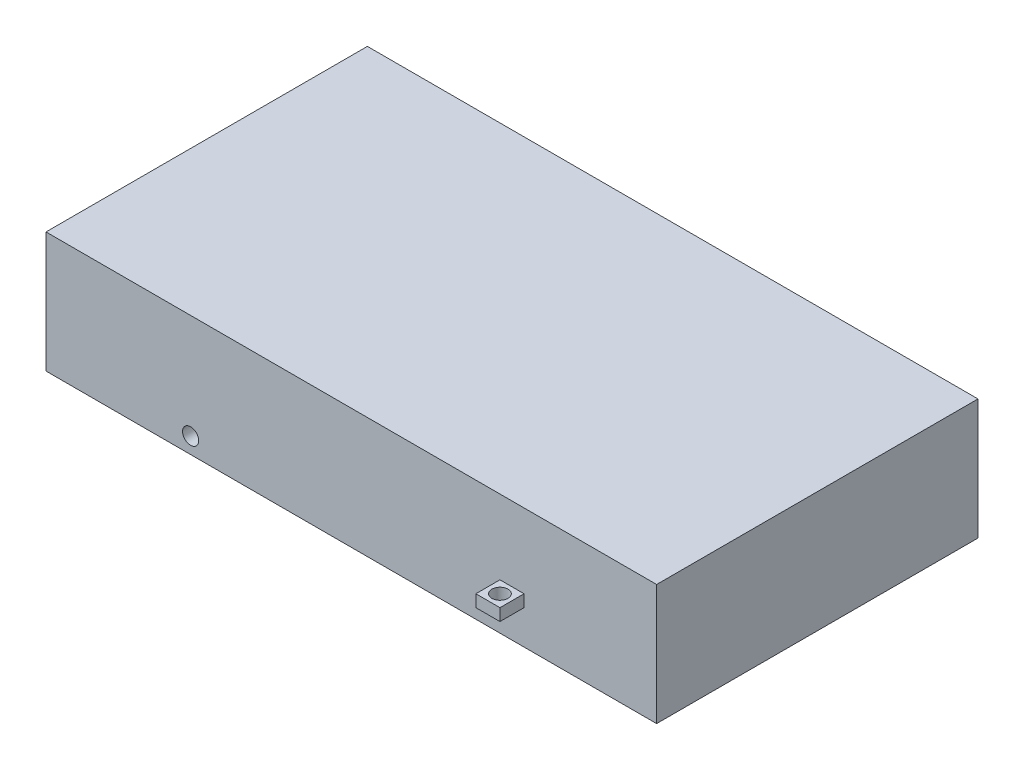
from build123d import *

# Parameters (mm, degrees)
SKETCH1_W           = 965.2
SKETCH1_H           = 508
BOSS_EXTRUDE1_DEPTH = 190.5
SKETCH2_W           = 38.1
SKETCH2_H           = 19.05
BOSS_EXTRUDE3_DEPTH = 38.1
CUT_EXTRUDE1_REACH  = 578.217
SKETCH3_R           = 12.7
CUT_EXTRUDE2_REACH  = 728.125
SKETCH2_4_R         = 12.7


with BuildPart() as part:
    # Sketch1 → Boss-Extrude1 (new body)
    with BuildSketch(Plane(origin=(0, 0, 0), x_dir=(1, 0, 0), z_dir=(0, 1, 0))):
        Rectangle(SKETCH1_W, SKETCH1_H)
    extrude(amount=BOSS_EXTRUDE1_DEPTH)

    # Sketch2 → Boss-Extrude3 (add)
    with BuildSketch(Plane.XY.offset(254)):
        with Locations((254, 63.5)):
            Rectangle(SKETCH2_W, SKETCH2_H)
    boss_extrude3 = extrude(amount=BOSS_EXTRUDE3_DEPTH)

    # Sketch3 → Cut-Extrude1 (cut, up to next)
    with BuildSketch(Plane(origin=(0, 73.025, 0), x_dir=(1, 0, 0), z_dir=(0, 1, 0)), mode=Mode.PRIVATE) as cut_extrude1_sk1:
        with Locations((254, -273.05)):
            Circle(SKETCH3_R)
    cut_extrude1_tool1 = extrude(cut_extrude1_sk1.sketch, amount=-CUT_EXTRUDE1_REACH, mode=Mode.PRIVATE) & part.part
    cut_extrude1 = cut_extrude1_tool1.solids().sort_by_distance((254, 73.025, 273.05))[0]
    add(cut_extrude1, mode=Mode.SUBTRACT)

    # Sketch2_4 → Cut-Extrude2 (cut, up to next)
    with BuildSketch(Plane.XY.offset(254), mode=Mode.PRIVATE) as cut_extrude2_sk1:
        with Locations((-254, 25.4)):
            Circle(SKETCH2_4_R)
    cut_extrude2_tool1 = extrude(cut_extrude2_sk1.sketch, amount=-CUT_EXTRUDE2_REACH, mode=Mode.PRIVATE) & part.part
    add(cut_extrude2_tool1.solids().sort_by_distance((-254, 25.4, 254))[0], mode=Mode.SUBTRACT)

    # Mirror2: Boss-Extrude3, Cut-Extrude1 across plane
    add(boss_extrude3.mirror(Plane.XY))
    add(cut_extrude1.mirror(Plane.XY), mode=Mode.SUBTRACT)


solid = part.part
